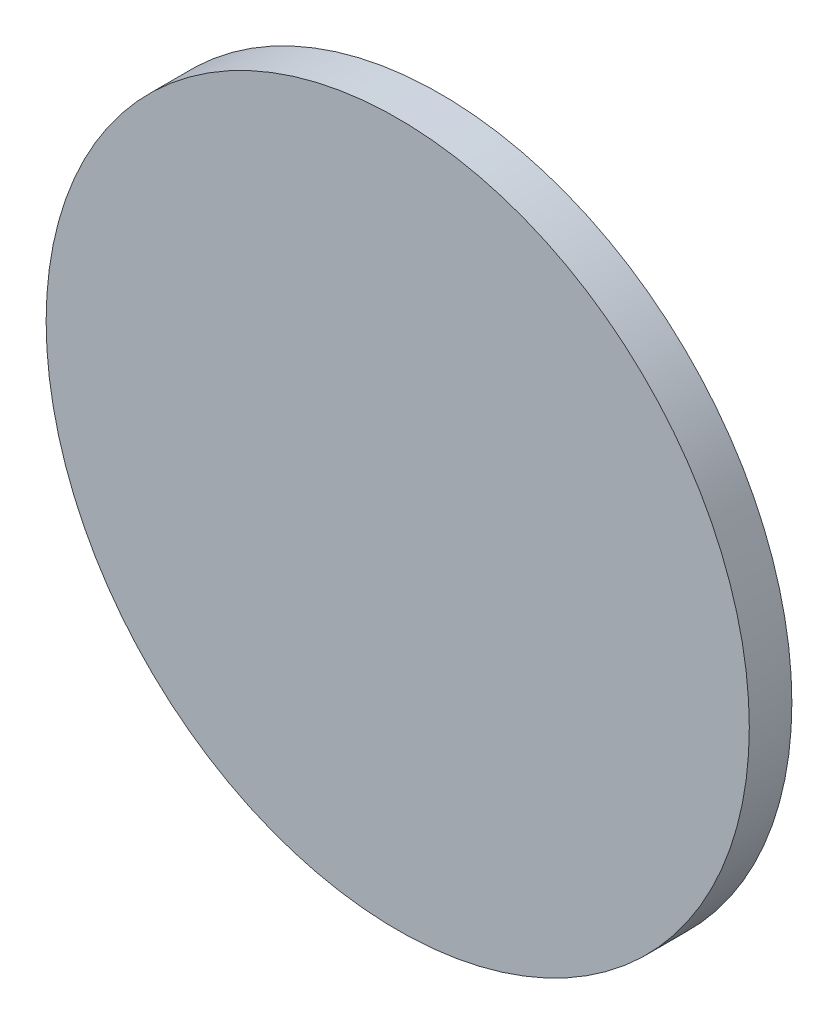
from build123d import *

# Parameters (mm, degrees)
SKETCH_1_R      = 19
EXTRUDE_1_DEPTH = 2.3


with BuildPart() as part:
    # 草图1 → 凸台-拉伸1 (new body)
    with BuildSketch(Plane.XY):
        with Locations((108.614983942, 61.565570069)):
            Circle(SKETCH_1_R)
    extrude(amount=EXTRUDE_1_DEPTH)


solid = part.part
